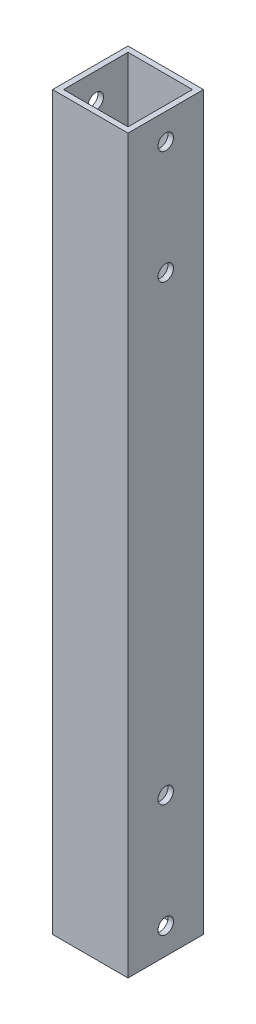
from build123d import *

# Parameters (mm, degrees)
SKETCH1_W           = 20
SKETCH1_H           = 20
SKETCH1_W_2         = 17.1
SKETCH1_H_2         = 17.1
BOSS_EXTRUDE1_DEPTH = 194
SKETCH2_R           = 2.05
CUT_EXTRUDE1_DEPTH  = 21


with BuildPart() as part:
    # Sketch1 → Boss-Extrude1 (new body)
    with BuildSketch(Plane(origin=(0, 0, 0), x_dir=(1, 0, 0), z_dir=(0, 1, 0))):
        with Locations((10, 10)):
            Rectangle(SKETCH1_W, SKETCH1_H)
        with Locations((10, 10)):
            Rectangle(SKETCH1_W_2, SKETCH1_H_2, mode=Mode.SUBTRACT)
    extrude(amount=BOSS_EXTRUDE1_DEPTH)

    # Sketch2 → Cut-Extrude1 (cut, through all)
    with BuildSketch(Plane.ZY):
        with Locations((-10, 187)):
            Circle(SKETCH2_R)
        with Locations((-10, 157)):
            Circle(SKETCH2_R)
        with Locations((-10, 37)):
            Circle(SKETCH2_R)
        with Locations((-10, 7)):
            Circle(SKETCH2_R)
    extrude(amount=-CUT_EXTRUDE1_DEPTH, mode=Mode.SUBTRACT)


solid = part.part
